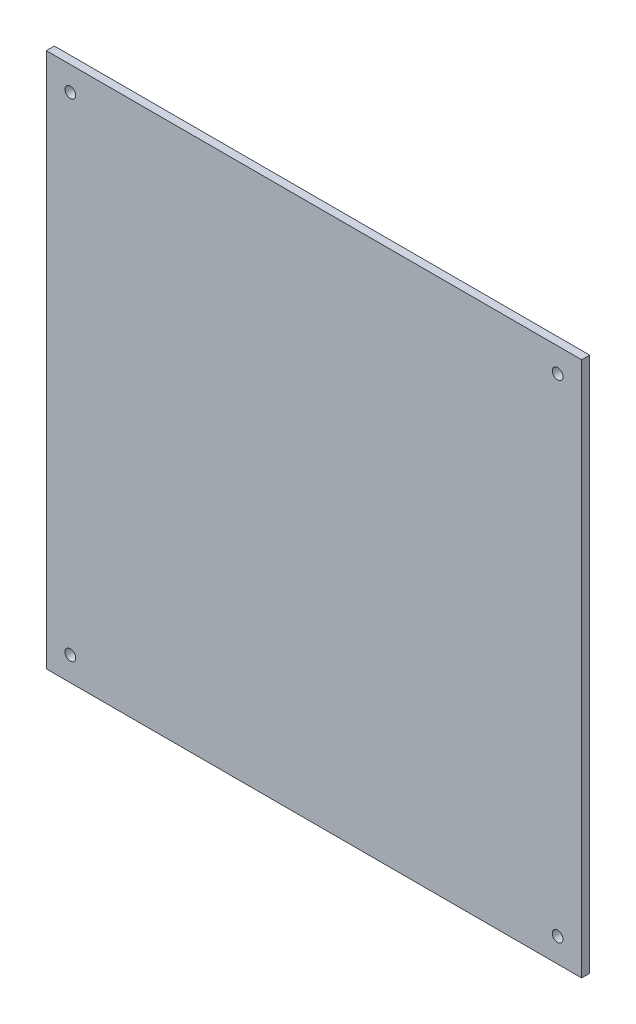
from build123d import *

# Parameters (mm, degrees)
ESQUISSE1_W                  = 200
ESQUISSE1_H                  = 200
BOSS_EXTRU_1_DEPTH           = 3
ESQUISSE2_R                  = 2
ENL_V_MAT_EXTRU_1_DEPTH      = 1
ENL_V_MAT_EXTRU_1_DEPTH_BACK = 4


with BuildPart() as part:
    # Esquisse1 → Boss.-Extru.1 (new body)
    with BuildSketch(Plane.XY):
        with Locations((100, 100)):
            Rectangle(ESQUISSE1_W, ESQUISSE1_H)
    extrude(amount=BOSS_EXTRU_1_DEPTH)

    # Esquisse2 → Enlèv. mat.-Extru.1 (cut, two sides)
    with BuildSketch(Plane.XY.offset(3)) as enl_v_mat_extru_1_sk:
        with Locations((9, 191)):
            Circle(ESQUISSE2_R)
        with Locations((191, 191)):
            Circle(ESQUISSE2_R)
        with Locations((191, 9)):
            Circle(ESQUISSE2_R)
        with Locations((9, 9)):
            Circle(ESQUISSE2_R)
    extrude(amount=ENL_V_MAT_EXTRU_1_DEPTH, mode=Mode.SUBTRACT)
    extrude(enl_v_mat_extru_1_sk.sketch, amount=-ENL_V_MAT_EXTRU_1_DEPTH_BACK, mode=Mode.SUBTRACT)


solid = part.part
